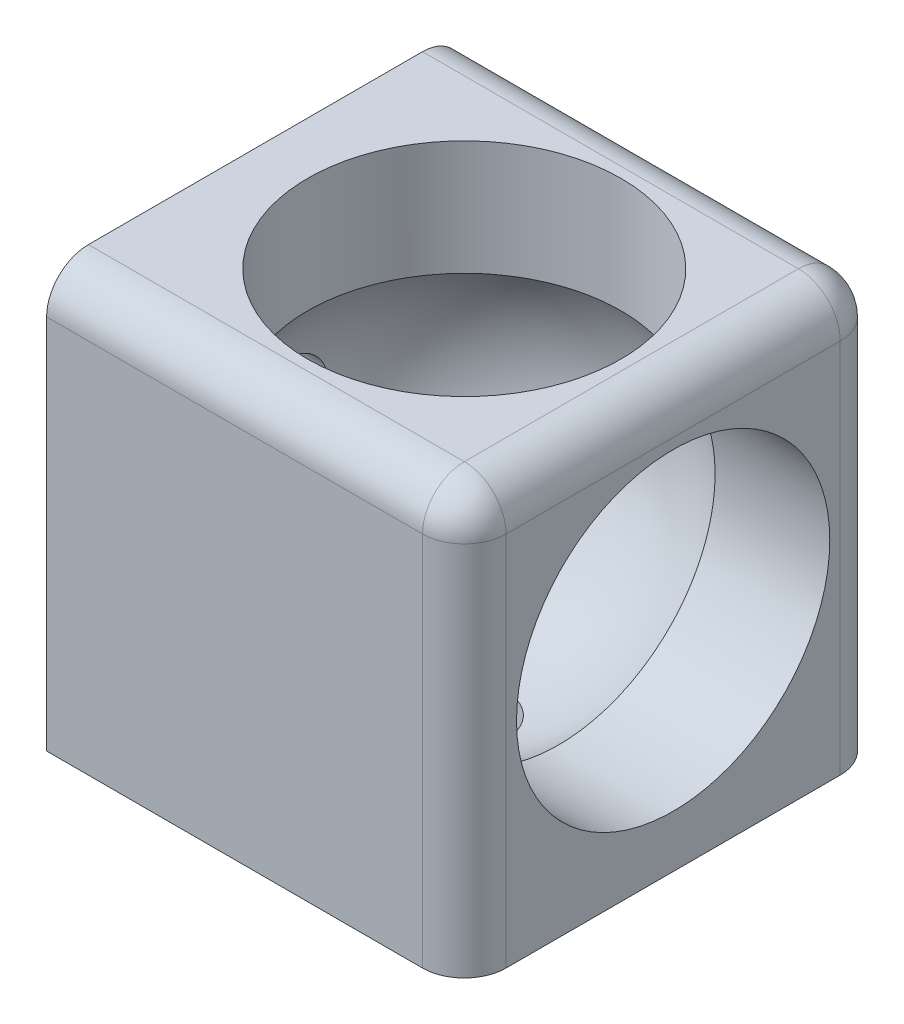
from build123d import *

# Parameters (mm, degrees)
SKETCH1_W           = 40
SKETCH1_H           = 40
BOSS_EXTRUDE1_DEPTH = 20
FILLET1_R           = 4
SKETCH12_R          = 15
CUT_EXTRUDE2_DEPTH  = 20
SKETCH13_R          = 15
CUT_EXTRUDE3_DEPTH  = 20
SKETCH16_R          = 4
CUT_EXTRUDE6_DEPTH  = 20
SKETCH17_R          = 4
CUT_EXTRUDE7_DEPTH  = 20


with BuildPart() as part:
    # Sketch1 → Boss-Extrude1 (new body, symmetric)
    with BuildSketch(Plane(origin=(0, 0, 0), x_dir=(1, 0, 0), z_dir=(0, 1, 0))):
        Rectangle(SKETCH1_W, SKETCH1_H)
    extrude(amount=BOSS_EXTRUDE1_DEPTH, both=True)

    # Fillet1
    fillet1_edges = [part.edges().sort_by_distance(p)[0] for p in [
        (20, 20, 0),
        (0, 20, -20),
        (20, 0, -20),
        (20, 0, 20),
        (0, 20, 20),
    ]]
    fillet(fillet1_edges, radius=FILLET1_R)

    # Sketch2 → Cut-Revolve1 (revolve, cut)
    with BuildSketch(Plane(origin=(0, 0, 0), x_dir=(1, 0, 0), z_dir=(0, 1, 0))):
        with BuildLine():
            Line((0, 17.5), (0, -17.5))
            ThreePointArc((0, -17.5), (-17.5, 0), (0, 17.5))
        make_face()
    revolve(axis=Axis((0, 0, -20.989422068), (0, 0, 1)), mode=Mode.SUBTRACT)

    # Sketch12 → Cut-Extrude2 (cut)
    with BuildSketch(Plane(origin=(0, 20, 0), x_dir=(1, 0, 0), z_dir=(0, 1, 0))):
        Circle(SKETCH12_R)
    extrude(amount=-CUT_EXTRUDE2_DEPTH, mode=Mode.SUBTRACT)

    # Sketch13 → Cut-Extrude3 (cut)
    with BuildSketch(Plane(origin=(20, 0, 0), x_dir=(0, 0, -1), z_dir=(1, 0, 0))):
        Circle(SKETCH13_R)
    extrude(amount=-CUT_EXTRUDE3_DEPTH, mode=Mode.SUBTRACT)

    # Sketch16 → Cut-Extrude6 (cut)
    with BuildSketch(Plane.XZ.offset(20)):
        Circle(SKETCH16_R)
    extrude(amount=-CUT_EXTRUDE6_DEPTH, mode=Mode.SUBTRACT)

    # Sketch17 → Cut-Extrude7 (cut)
    with BuildSketch(Plane.ZY.offset(20)):
        Circle(SKETCH17_R)
    extrude(amount=-CUT_EXTRUDE7_DEPTH, mode=Mode.SUBTRACT)


solid = part.part
